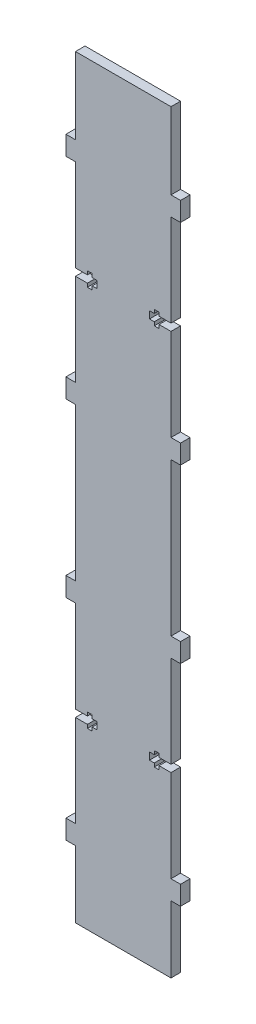
from build123d import *

# Parameters (mm, degrees)
BOSS_EXTRUDE1_DEPTH = 6.35
CUT_EXTRUDE1_DEPTH  = 6.35


with BuildPart() as part:
    # Sketch1 → Boss-Extrude1 (new body)
    with BuildSketch(Plane.XY):
        Polygon((76.2, 190.5), (76.2, 203.2), (69.85, 203.2), (69.85, 304.8), (76.2, 304.8), (76.2, 317.5), (69.85, 317.5), (69.85, 444.5), (76.2, 444.5), (76.2, 457.2), (69.85, 457.2), (69.85, 508), (6.35, 508), (6.35, 457.2), (0, 457.2), (0, 444.5), (6.35, 444.5), (6.35, 317.5), (0, 317.5), (0, 304.8), (6.35, 304.8), (6.35, 203.2), (0, 203.2), (0, 190.5), (6.35, 190.5), (6.35, 63.5), (0, 63.5), (0, 50.8), (6.35, 50.8), (6.35, 6.35), (69.85, 6.35), (69.85, 50.8), (76.2, 50.8), (76.2, 63.5), (69.85, 63.5), (69.85, 190.5), align=None)
    extrude(amount=BOSS_EXTRUDE1_DEPTH)

    # Sketch2 → Cut-Extrude1 (cut)
    with BuildSketch(Plane(origin=(0, 0, 0), x_dir=(-1, 0, 0), z_dir=(0, 0, -1))):
        Polygon((-58.7375, 124.61875), (-55.5625, 124.61875), (-55.5625, 129.38125), (-58.7375, 129.38125), (-58.7375, 131.7625), (-61.9125, 131.7625), (-61.9125, 129.38125), (-69.85, 129.38125), (-69.85, 124.61875), (-61.9125, 124.61875), (-61.9125, 122.2375), (-58.7375, 122.2375), align=None)
        Polygon((-6.35, 124.61875), (-14.2875, 124.61875), (-14.2875, 122.2375), (-17.4625, 122.2375), (-17.4625, 124.61875), (-20.6375, 124.61875), (-20.6375, 129.38125), (-17.4625, 129.38125), (-17.4625, 131.7625), (-14.2875, 131.7625), (-14.2875, 129.38125), (-6.35, 129.38125), align=None)
        Polygon((-17.4625, 383.38125), (-20.6375, 383.38125), (-20.6375, 378.61875), (-17.4625, 378.61875), (-17.4625, 376.2375), (-14.2875, 376.2375), (-14.2875, 378.61875), (-6.35, 378.61875), (-6.35, 383.38125), (-14.2875, 383.38125), (-14.2875, 385.7625), (-17.4625, 385.7625), align=None)
        Polygon((-69.85, 383.38125), (-61.9125, 383.38125), (-61.9125, 385.7625), (-58.7375, 385.7625), (-58.7375, 383.38125), (-55.5625, 383.38125), (-55.5625, 378.61875), (-58.7375, 378.61875), (-58.7375, 376.2375), (-61.9125, 376.2375), (-61.9125, 378.61875), (-69.85, 378.61875), align=None)
    extrude(amount=-CUT_EXTRUDE1_DEPTH, mode=Mode.SUBTRACT)


solid = part.part
